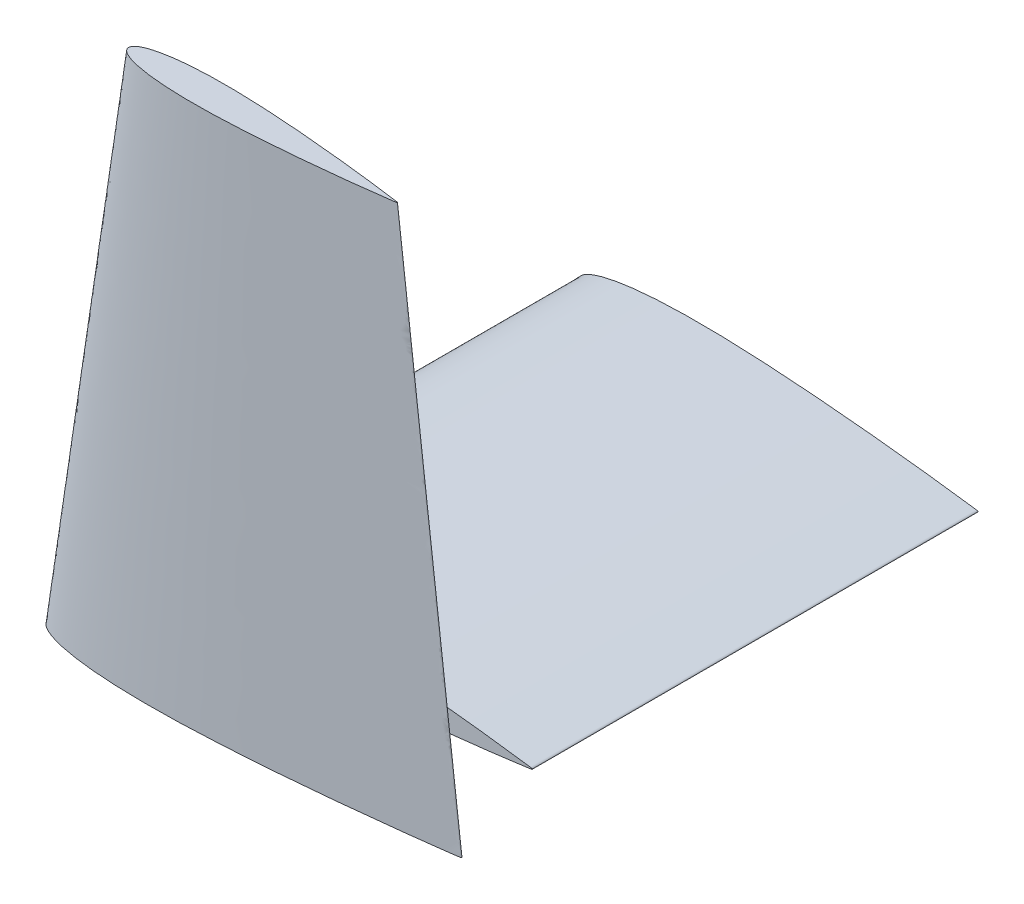
from build123d import *

# Parameters (mm, degrees)
BOSS_EXTRUDE1_DEPTH = 355.6


with BuildPart() as part:
    # Sketch2 → Boss-Extrude1 (new body)
    with BuildSketch(Plane.XY.offset(-61.341)):
        with BuildLine():
            add(Edge.make_bspline(
                [(318.77, 0.4016502), (318.651672051, 0.500810625), (317.887139521, 0.407183952), (316.525702267, 0.790429835), (314.029007456, 1.027310814), (310.665580368, 1.535686456), (306.332982445, 2.102999714), (301.108142881, 2.802187224), (295.00465514, 3.592552282), (288.066717306, 4.4725213), (280.334877508, 5.426678676), (271.857503414, 6.442111261), (262.686702585, 7.506224727), (252.87894916, 8.604531435), (242.494745532, 9.723621949), (231.598187206, 10.849597023), (220.25642858, 11.967923085), (208.539426289, 13.062902197), (196.51933871, 14.120159542), (184.270405083, 15.122019671), (171.867889749, 16.052147213), (159.388371015, 16.893273609), (146.908740176, 17.627811631), (134.505824677, 18.237204103), (122.256224526, 18.705201007), (110.2351092, 19.016534527), (98.516766738, 19.155997955), (87.173201506, 19.112523415), (76.274349541, 18.877713447), (65.887298252, 18.445615875), (56.075981931, 17.815100401), (46.900701285, 16.988064202), (38.417602501, 15.970966467), (30.678392783, 14.772461193), (23.72996987, 13.405065743), (17.613059426, 11.884241622), (12.362420389, 10.224818762), (8.00472945, 8.442252382), (4.553883407, 6.548602381), (2.01519229, 4.54013128), (0.389181285, 2.368249597), (-0.181372316, 0), (0.389181285, -2.368249597), (2.01519229, -4.54013128), (4.553883407, -6.548602381), (8.00472945, -8.442252382), (12.362420389, -10.224818762), (17.613059426, -11.884241622), (23.72996987, -13.405065743), (30.678392783, -14.772461193), (38.417602501, -15.970966467), (46.900701285, -16.988064202), (56.075981931, -17.815100401), (65.887298252, -18.445615875), (76.274349541, -18.877713447), (87.173201506, -19.112523415), (98.516766738, -19.155997955), (110.2351092, -19.016534527), (122.256224526, -18.705201007), (134.505824677, -18.237204103), (146.908740176, -17.627811631), (159.388371015, -16.893273609), (171.867889749, -16.052147213), (184.270405083, -15.122019671), (196.51933871, -14.120159542), (208.539426289, -13.062902197), (220.25642858, -11.967923085), (231.598187206, -10.849597023), (242.494745532, -9.723621949), (252.87894916, -8.604531435), (262.686702585, -7.506224727), (271.857503414, -6.442111261), (280.334877508, -5.426678676), (288.066717306, -4.4725213), (295.00465514, -3.592552282), (301.108142881, -2.802187224), (306.332982445, -2.102999714), (310.665580368, -1.535686456), (314.029007456, -1.027310814), (316.525702267, -0.790429835), (317.887139521, -0.407183952), (318.96162857, -0.538768719), (318.96162857, 0.241062861), (318.77, 0.4016502)],
                knots=[0, 0, 0, 0, 0.000762215, 0.003044706, 0.006832246, 0.012101176, 0.018817536, 0.026939455, 0.036414848, 0.047184629, 0.059180413, 0.072327874, 0.086544061, 0.10174058, 0.117823336, 0.134691452, 0.152240154, 0.17036129, 0.188941008, 0.207865435, 0.227016078, 0.246275696, 0.265524943, 0.284644966, 0.303520118, 0.322034575, 0.340078353, 0.357542593, 0.374325482, 0.390329891, 0.40546389, 0.419643801, 0.432793371, 0.444843817, 0.455737921, 0.465428653, 0.47388632, 0.481101634, 0.487101684, 0.491975368, 0.495930678, 0.499382808, 0.502834938, 0.506790248, 0.511663932, 0.517663982, 0.524879296, 0.533336963, 0.543027695, 0.553921799, 0.565972245, 0.579121815, 0.593301726, 0.608435725, 0.624440134, 0.641223023, 0.658687263, 0.676731041, 0.695245498, 0.71412065, 0.733240673, 0.75248992, 0.771749538, 0.790900181, 0.809824608, 0.828404326, 0.846525462, 0.864074164, 0.88094228, 0.897025036, 0.912221555, 0.926437743, 0.939585203, 0.951580988, 0.962350768, 0.971826161, 0.979948081, 0.98666444, 0.991933371, 0.99572091, 0.998003402, 0.998765616, 1, 1, 1, 1], degree=3))
        make_face()
    extrude(amount=BOSS_EXTRUDE1_DEPTH)


with BuildPart() as body_2:
    # Sketch3 → Loft1 section 0
    with BuildSketch(Plane(origin=(0, -60.96, 0), x_dir=(1, 0, 0), z_dir=(0, 1, 0))):
        with BuildLine():
            add(Edge.make_bspline(
                [(290.83, -322.1655482), (290.707900642, -322.063227283), (289.919000541, -322.159838074), (288.514170865, -321.764377182), (285.937900124, -321.519946212), (282.467272172, -320.995367362), (277.996583479, -320.409972406), (272.605215164, -319.688500035), (266.307193949, -318.87294406), (259.148126622, -317.96492822), (251.169853683, -316.980359454), (242.422284399, -315.932562484), (232.95918713, -314.834533051), (222.838835986, -313.701220552), (212.123661724, -312.546461813), (200.879802735, -311.384599088), (189.176553794, -310.230629167), (177.086101231, -309.100750323), (164.68290329, -308.009795532), (152.043565404, -306.976003607), (139.245750776, -306.016230565), (126.368478458, -305.14829536), (113.491090461, -304.390345767), (100.692862913, -303.761530428), (88.05283726, -303.278617288), (75.648578816, -302.957360787), (63.556743367, -302.813452309), (51.851630239, -302.858312492), (40.605404506, -303.100606443), (29.887291822, -303.546476049), (19.763264224, -304.197087634), (10.295544354, -305.050483553), (1.542067919, -306.099998745), (-6.443809838, -307.33670339), (-13.613696429, -308.747681166), (-19.925568162, -310.316977769), (-25.343558244, -312.029290601), (-29.840139731, -313.868671845), (-33.400972898, -315.822677224), (-36.020578473, -317.895163341), (-37.698414531, -320.136268344), (-38.287153107, -322.58), (-37.698414531, -325.023731656), (-36.020578473, -327.264836659), (-33.400972898, -329.337322776), (-29.840139731, -331.291328155), (-25.343558244, -333.130709399), (-19.925568162, -334.843022231), (-13.613696429, -336.412318834), (-6.443809838, -337.82329661), (1.542067919, -339.060001255), (10.295544354, -340.109516447), (19.763264224, -340.962912366), (29.887291822, -341.613523951), (40.605404506, -342.059393557), (51.851630239, -342.301687508), (63.556743367, -342.346547691), (75.648578816, -342.202639213), (88.05283726, -341.881382712), (100.692862913, -341.398469572), (113.491090461, -340.769654233), (126.368478458, -340.01170464), (139.245750776, -339.143769435), (152.043565404, -338.183996393), (164.68290329, -337.150204468), (177.086101231, -336.059249677), (189.176553794, -334.929370833), (200.879802735, -333.775400912), (212.123661724, -332.613538187), (222.838835986, -331.458779448), (232.95918713, -330.325466949), (242.422284399, -329.227437516), (251.169853683, -328.179640546), (259.148126622, -327.19507178), (266.307193949, -326.28705594), (272.605215164, -325.471499965), (277.996583479, -324.750027594), (282.467272172, -324.164632638), (285.937900124, -323.640053788), (288.514170865, -323.395622818), (289.919000541, -323.000161926), (291.027736254, -323.135940631), (291.027736254, -322.33125386), (290.83, -322.1655482)],
                knots=[0, 0, 0, 0, 0.000762215, 0.003044706, 0.006832246, 0.012101176, 0.018817536, 0.026939455, 0.036414848, 0.047184629, 0.059180413, 0.072327874, 0.086544061, 0.10174058, 0.117823336, 0.134691452, 0.152240154, 0.17036129, 0.188941008, 0.207865435, 0.227016078, 0.246275696, 0.265524943, 0.284644966, 0.303520118, 0.322034575, 0.340078353, 0.357542593, 0.374325482, 0.390329891, 0.40546389, 0.419643801, 0.432793371, 0.444843817, 0.455737921, 0.465428653, 0.47388632, 0.481101634, 0.487101684, 0.491975368, 0.495930678, 0.499382808, 0.502834938, 0.506790248, 0.511663932, 0.517663982, 0.524879296, 0.533336963, 0.543027695, 0.553921799, 0.565972245, 0.579121815, 0.593301726, 0.608435725, 0.624440134, 0.641223023, 0.658687263, 0.676731041, 0.695245498, 0.71412065, 0.733240673, 0.75248992, 0.771749538, 0.790900181, 0.809824608, 0.828404326, 0.846525462, 0.864074164, 0.88094228, 0.897025036, 0.912221555, 0.926437743, 0.939585203, 0.951580988, 0.962350768, 0.971826161, 0.979948081, 0.98666444, 0.991933371, 0.99572091, 0.998003402, 0.998765616, 1, 1, 1, 1], degree=3))
        make_face()
    # Sketch4 → Loft1 section 1
    with BuildSketch(Plane(origin=(0, 365.76, 0), x_dir=(-1, 0, 0), z_dir=(0, -1, 0))):
        with BuildLine():
            add(Edge.make_bspline(
                [(-239.522, -322.31020628), (-239.65071943, -322.418074907), (-239.65071943, -322.941898032), (-238.928971009, -322.853510814), (-238.014475706, -323.110942112), (-236.337412976, -323.27005818), (-234.078154781, -323.611540783), (-231.167891794, -323.992612557), (-227.658298365, -324.462266), (-223.558505405, -324.9931646), (-218.898201346, -325.584251359), (-213.7046229, -326.225171414), (-208.010259265, -326.907250831), (-201.850111776, -327.622029836), (-195.262114854, -328.359776892), (-188.286908752, -329.111484704), (-180.967547263, -329.867816965), (-173.349138879, -330.619011284), (-165.478674392, -331.354523149), (-157.404623532, -332.064696808), (-149.176853773, -332.737659428), (-140.845921162, -333.362438327), (-132.463264355, -333.927433986), (-124.080532246, -334.420832833), (-115.749330839, -334.830169768), (-107.521113367, -335.144529441), (-99.446372156, -335.35365626), (-91.575007458, -335.447335678), (-83.955385553, -335.418133258), (-76.634483397, -335.260408315), (-69.657364483, -334.970162696), (-63.066974317, -334.546637162), (-56.903817676, -333.991106073), (-51.205608692, -333.307908153), (-46.007079774, -332.502856403), (-41.339732749, -331.584358901), (-37.230923582, -330.562801344), (-33.704000309, -329.448145192), (-30.776882013, -328.250771919), (-28.458903356, -326.978782317), (-26.753631156, -325.629665872), (-25.661418186, -324.170784391), (-25.278169831, -322.58), (-25.661418186, -320.989215609), (-26.753631156, -319.530334128), (-28.458903356, -318.181217683), (-30.776882013, -316.909228081), (-33.704000309, -315.711854808), (-37.230923582, -314.597198656), (-41.339732749, -313.575641099), (-46.007079774, -312.657143597), (-51.205608692, -311.852091847), (-56.903817676, -311.168893927), (-63.066974317, -310.613362838), (-69.657364483, -310.189837304), (-76.634483397, -309.899591685), (-83.955385553, -309.741866742), (-91.575007458, -309.712664322), (-99.446372156, -309.80634374), (-107.521113367, -310.015470559), (-115.749330839, -310.329830232), (-124.080532246, -310.739167167), (-132.463264355, -311.232566014), (-140.845921162, -311.797561673), (-149.176853773, -312.422340572), (-157.404623532, -313.095303192), (-165.478674392, -313.805476851), (-173.349138879, -314.540988716), (-180.967547263, -315.292183035), (-188.286908752, -316.048515296), (-195.262114854, -316.800223108), (-201.850111776, -317.537970164), (-208.010259265, -318.252749169), (-213.7046229, -318.934828586), (-218.898201346, -319.575748641), (-223.558505405, -320.1668354), (-227.658298365, -320.697734), (-231.167891794, -321.167387443), (-234.078154781, -321.548459217), (-236.337412976, -321.88994182), (-238.014475706, -322.049057888), (-238.928971009, -322.306489186), (-239.442517561, -322.243598919), (-239.522, -322.31020628)],
                knots=[0, 0, 0, 0, 0.001234384, 0.001996598, 0.00427909, 0.008066629, 0.01333556, 0.020051919, 0.028173839, 0.037649232, 0.048419012, 0.060414797, 0.073562257, 0.087778445, 0.102974964, 0.11905772, 0.135925836, 0.153474538, 0.171595674, 0.190175392, 0.209099819, 0.228250462, 0.24751008, 0.266759327, 0.28587935, 0.304754502, 0.323268959, 0.341312737, 0.358776977, 0.375559866, 0.391564275, 0.406698274, 0.420878185, 0.434027755, 0.446078201, 0.456972305, 0.466663037, 0.475120704, 0.482336018, 0.488336068, 0.493209752, 0.497165062, 0.500617192, 0.504069322, 0.508024632, 0.512898316, 0.518898366, 0.52611368, 0.534571347, 0.544262079, 0.555156183, 0.567206629, 0.580356199, 0.59453611, 0.609670109, 0.625674518, 0.642457407, 0.659921647, 0.677965425, 0.696479882, 0.715355034, 0.734475057, 0.753724304, 0.772983922, 0.792134565, 0.811058992, 0.82963871, 0.847759846, 0.865308548, 0.882176664, 0.89825942, 0.913455939, 0.927672126, 0.940819587, 0.952815371, 0.963585152, 0.973060545, 0.981182464, 0.987898824, 0.993167754, 0.996955294, 0.999237785, 1, 1, 1, 1], degree=3))
        make_face()
    loft()


solid = Compound([part.part, body_2.part])
